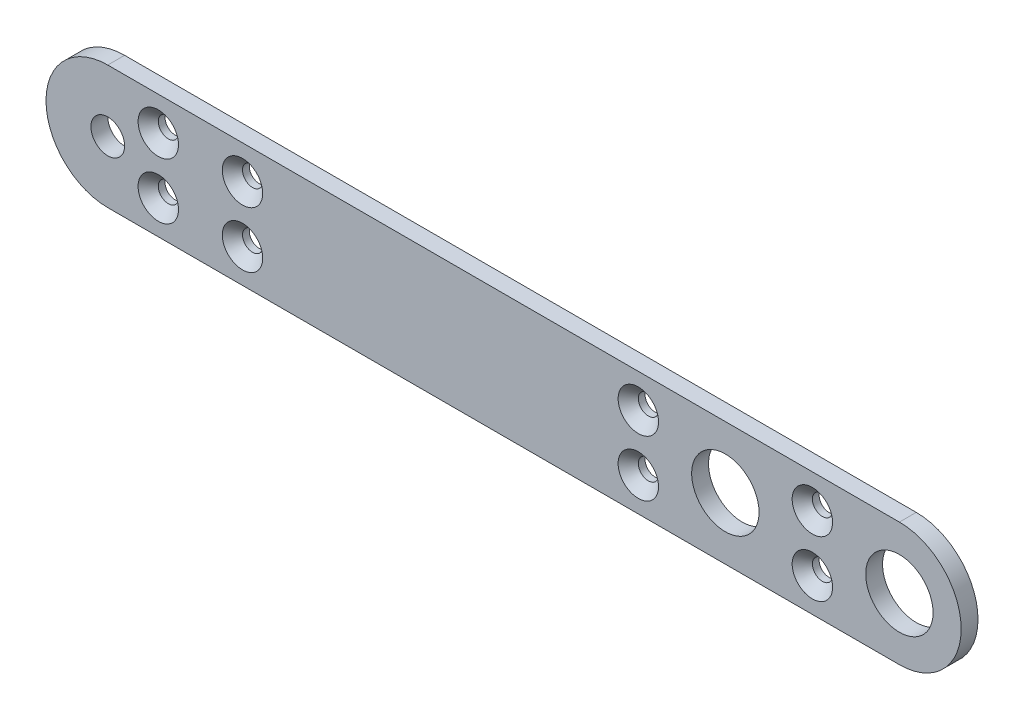
from build123d import *

# Parameters (mm, degrees)
SKETCH1_R                                    = 1.5
SKETCH1_R_2                                  = 3
BOSS_EXTRUDE1_DEPTH                          = 1.5
CSK_FOR_M1_6_COUNTERSUNK_FLAT_HEAD_S_2_COUNT = 2
CSK_FOR_M1_6_COUNTERSUNK_FLAT_HEAD_S_2_PITCH = 15.5
CSK_FOR_M1_6_COUNTERSUNK_FLAT_HEAD_S_3_COUNT = 2
CSK_FOR_M1_6_COUNTERSUNK_FLAT_HEAD_S_3_PITCH = 58.25
CSK_FOR_M1_6_COUNTERSUNK_FLAT_HEAD_S_4_COUNT = 2
CSK_FOR_M1_6_COUNTERSUNK_FLAT_HEAD_S_4_PITCH = 50.75


with BuildPart() as part:
    # Sketch1 → Boss-Extrude1 (new body)
    with BuildSketch(Plane.XY):
        with BuildLine():
            Line((15.5, 5.5), (-55, 5.5))
            ThreePointArc((-55, 5.5), (-60.5, 0), (-55, -5.5))
            Line((-55, -5.5), (15.5, -5.5))
            ThreePointArc((15.5, -5.5), (21, 0), (15.5, 5.5))
        make_face()
        with Locations((-55, 0)):
            Circle(SKETCH1_R, mode=Mode.SUBTRACT)
        Circle(SKETCH1_R_2, mode=Mode.SUBTRACT)
        with Locations((15.5, 0)):
            Circle(SKETCH1_R_2, mode=Mode.SUBTRACT)
    extrude(amount=BOSS_EXTRUDE1_DEPTH)

    # Sketch2 → CSK for M1.6 Countersunk Flat Head Screw1 (revolve, cut)
    with BuildSketch(Plane(origin=(7.75, 2.5, 1.5), x_dir=(0, -1, 0), z_dir=(1, 0, 0))):
        Polygon((0, 0), (0, 1.5), (0.9, 1.5), (0.9, 0.9), (1.8, 0), align=None)
    csk_for_m1_6_countersunk_flat_head_screw = revolve(axis=Axis((7.75, 2.5, 7.85), (0, 0, -1)), mode=Mode.SUBTRACT)

    # CSK for M1.6 Countersunk Flat Head S 2: CSK for M1.6 Countersunk Flat Head Screw1 ×2
    with Locations(*[(-i * CSK_FOR_M1_6_COUNTERSUNK_FLAT_HEAD_S_2_PITCH, 0, 0) for i in range(1, CSK_FOR_M1_6_COUNTERSUNK_FLAT_HEAD_S_2_COUNT)]):
        add(csk_for_m1_6_countersunk_flat_head_screw, mode=Mode.SUBTRACT)

    # CSK for M1.6 Countersunk Flat Head S 3: CSK for M1.6 Countersunk Flat Head Screw1 ×2
    with Locations(*[(-i * CSK_FOR_M1_6_COUNTERSUNK_FLAT_HEAD_S_3_PITCH, 0, 0) for i in range(1, CSK_FOR_M1_6_COUNTERSUNK_FLAT_HEAD_S_3_COUNT)]):
        add(csk_for_m1_6_countersunk_flat_head_screw, mode=Mode.SUBTRACT)

    # CSK for M1.6 Countersunk Flat Head S 4: CSK for M1.6 Countersunk Flat Head Screw1 ×2
    with Locations(*[(-i * CSK_FOR_M1_6_COUNTERSUNK_FLAT_HEAD_S_4_PITCH, 0, 0) for i in range(1, CSK_FOR_M1_6_COUNTERSUNK_FLAT_HEAD_S_4_COUNT)]):
        add(csk_for_m1_6_countersunk_flat_head_screw, mode=Mode.SUBTRACT)

    # Mirror1: CSK for M1.6 Countersunk Flat Head Screw1 across plane
    add(csk_for_m1_6_countersunk_flat_head_screw.mirror(Plane.ZX), mode=Mode.SUBTRACT)

    # Mirror1 copy 1 sketch → Mirror1 copy 1 (revolve, cut)
    with BuildSketch(Plane(origin=(-7.75, -2.5, 1.5), x_dir=(0, 1, 0), z_dir=(1, 0, 0))):
        Polygon((0, 0), (0, -1.5), (0.9, -1.5), (0.9, -0.9), (1.8, 0), align=None)
    revolve(axis=Axis((-7.75, -2.5, 7.85), (0, 0, 1)), mode=Mode.SUBTRACT)

    # Mirror1 copy 2 sketch → Mirror1 copy 2 (revolve, cut)
    with BuildSketch(Plane(origin=(-50.5, -2.5, 1.5), x_dir=(0, 1, 0), z_dir=(1, 0, 0))):
        Polygon((0, 0), (0, -1.5), (0.9, -1.5), (0.9, -0.9), (1.8, 0), align=None)
    revolve(axis=Axis((-50.5, -2.5, 7.85), (0, 0, 1)), mode=Mode.SUBTRACT)

    # Mirror1 copy 3 sketch → Mirror1 copy 3 (revolve, cut)
    with BuildSketch(Plane(origin=(-43, -2.5, 1.5), x_dir=(0, 1, 0), z_dir=(1, 0, 0))):
        Polygon((0, 0), (0, -1.5), (0.9, -1.5), (0.9, -0.9), (1.8, 0), align=None)
    revolve(axis=Axis((-43, -2.5, 7.85), (0, 0, 1)), mode=Mode.SUBTRACT)


solid = part.part
